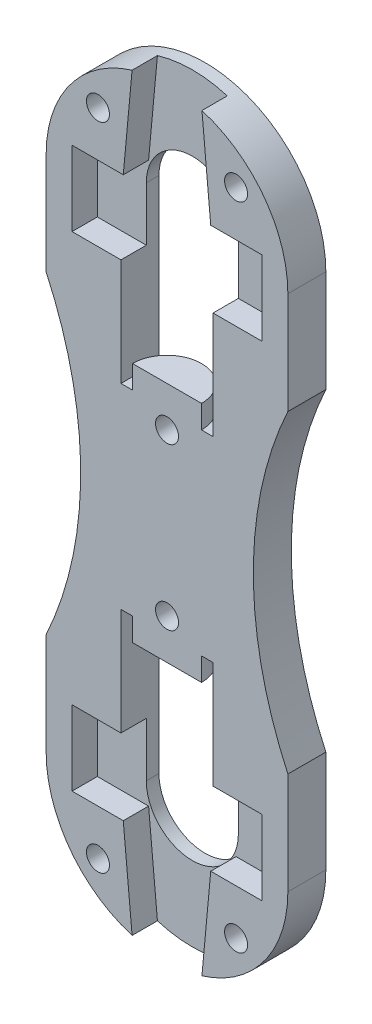
from build123d import *

# Parameters (mm, degrees)
SKETCH_1_R          = 1
EXTRUDE_1_DEPTH     = 3.3
CUT_EXTRUDE_1_DEPTH = 2.2
EXTRUDE_2_DEPTH     = 2


with BuildPart() as part:
    # 草图1 → 凸台-拉伸1 (new body)
    with BuildSketch(Plane.XY):
        with BuildLine():
            Line((10.5, -13.638181697), (10.5, -22.5))
            ThreePointArc((10.5, -22.5), (0, -33), (-10.5, -22.5))
            Line((-10.5, -22.5), (-10.5, -13.638181697))
            ThreePointArc((-10.5, -13.638181697), (-7.5, 0), (-10.5, 13.638181697))
            Line((-10.5, 13.638181697), (-10.5, 22.5))
            ThreePointArc((-10.5, 22.5), (0, 33), (10.5, 22.5))
            Line((10.5, 22.5), (10.5, 13.638181697))
            ThreePointArc((10.5, 13.638181697), (7.5, 0), (10.5, -13.638181697))
        make_face()
        with Locations((0, 7)):
            Circle(SKETCH_1_R, mode=Mode.SUBTRACT)
        with Locations((0, -7)):
            Circle(SKETCH_1_R, mode=Mode.SUBTRACT)
        with Locations((-6, 28.25)):
            Circle(SKETCH_1_R, mode=Mode.SUBTRACT)
        with Locations((6, 28.25)):
            Circle(SKETCH_1_R, mode=Mode.SUBTRACT)
        with Locations((6, -28.25)):
            Circle(SKETCH_1_R, mode=Mode.SUBTRACT)
        with Locations((-6, -28.25)):
            Circle(SKETCH_1_R, mode=Mode.SUBTRACT)
        with BuildLine():
            Line((-4, -22.499999544), (-4, -8.5))
            Line((-4, -8.5), (4, -8.5))
            Line((4, -8.5), (4, -22.500000456))
            ThreePointArc((4, -22.500000456), (-4.56e-07, -26.5), (-4, -22.499999544))
        make_face(mode=Mode.SUBTRACT)
        with BuildLine():
            Line((-4, 22.499999544), (-4, 8.5))
            Line((-4, 8.5), (4, 8.5))
            Line((4, 8.5), (4, 22.500000456))
            ThreePointArc((4, 22.500000456), (-4.56e-07, 26.5), (-4, 22.499999544))
        make_face(mode=Mode.SUBTRACT)
    extrude(amount=EXTRUDE_1_DEPTH)

    # 草图2 → 切除-拉伸1 (cut)
    with BuildSketch(Plane.XY.offset(3.3)):
        Polygon((-3.8, 24.3), (-2.871447866, 34.3), (2.871447866, 34.3), (3.8, 24.3), (8.25, 24.3), (8.25, 17.8), (-8.25, 17.8), (-8.25, 24.3), align=None)
        Polygon((3.8, -24.3), (8.25, -24.3), (8.25, -17.8), (-8.25, -17.8), (-8.25, -24.3), (-3.8, -24.3), (-2.871447866, -34.3), (2.871447866, -34.3), align=None)
    extrude(amount=-CUT_EXTRUDE_1_DEPTH, mode=Mode.SUBTRACT)

    # 草图3 → 凸台-拉伸2 (add)
    with BuildSketch(Plane(origin=(0, 8.5, 0), x_dir=(1, 0, 0), z_dir=(0, 1, 0))):
        with BuildLine():
            Line((-3, -3.3), (3, -3.3))
            ThreePointArc((3, -3.3), (0, -0.3), (-3, -3.3))
        make_face()
    extrude_2 = extrude(amount=EXTRUDE_2_DEPTH)

    # 镜向1: 凸台-拉伸2 across plane
    add(extrude_2.mirror(Plane.ZX))


solid = part.part
